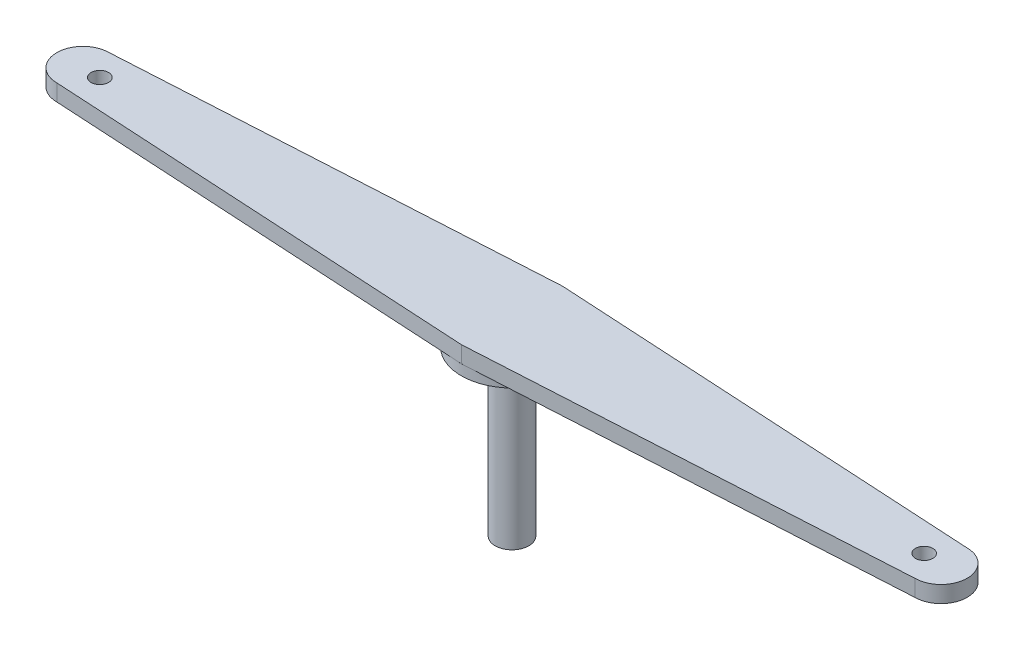
from build123d import *

# Parameters (mm, degrees)
BOSS_EXTRUDE1_DEPTH = 4.75
SKETCH1_4_R         = 4.75
BOSS_EXTRUDE2_DEPTH = 50
SKETCH3_R           = 14.5
BOSS_EXTRUDE3_DEPTH = 3
CUT_EXTRUDE1_REACH  = 56.75
SKETCH4_R           = 2.5
SKETCH5_R           = 2.5
CUT_EXTRUDE2_DEPTH  = 5
SKETCH6_R           = 2.5
BOSS_EXTRUDE5_DEPTH = 5
BOSS_EXTRUDE6_REACH = 56.75
SKETCH7_R           = 4.825
SKETCH8_R           = 2
CUT_EXTRUDE3_DEPTH  = 3


with BuildPart() as part:
    # Sketch1 → Boss-Extrude1 (new body)
    with BuildSketch(Plane(origin=(0, 0, 0), x_dir=(1, 0, 0), z_dir=(0, 1, 0))):
        with BuildLine():
            Line((0, 14.5), (-122.9, 7.5))
            ThreePointArc((-122.9, 7.5), (-130.4, 0), (-122.9, -7.5))
            Line((-122.9, -7.5), (0, -14.5))
            Line((0, -14.5), (122.9, -7.5))
            ThreePointArc((122.9, -7.5), (130.4, 0), (122.9, 7.5))
            Line((122.9, 7.5), (0, 14.5))
        make_face()
    extrude(amount=BOSS_EXTRUDE1_DEPTH)

    # Sketch1_4 → Boss-Extrude2 (add)
    with BuildSketch(Plane(origin=(0, 0, 0), x_dir=(1, 0, 0), z_dir=(0, 1, 0))):
        Circle(SKETCH1_4_R)
    extrude(amount=-BOSS_EXTRUDE2_DEPTH)

    # Sketch3 → Boss-Extrude3 (add)
    with BuildSketch(Plane.XZ):
        Circle(SKETCH3_R)
    extrude(amount=BOSS_EXTRUDE3_DEPTH)

    # Sketch4 → Cut-Extrude1 (cut, up to next)
    with BuildSketch(Plane(origin=(0, 4.75, 0), x_dir=(1, 0, 0), z_dir=(0, 1, 0)), mode=Mode.PRIVATE) as cut_extrude1_sk1:
        with Locations((111.778793877, 0)):
            Circle(SKETCH4_R)
    cut_extrude1_tool1 = extrude(cut_extrude1_sk1.sketch, amount=-CUT_EXTRUDE1_REACH, mode=Mode.PRIVATE) & part.part
    add(cut_extrude1_tool1.solids().sort_by_distance((111.778794, 4.75, 0))[0], mode=Mode.SUBTRACT)
    # Sketch4 → Cut-Extrude1 (cut, up to next)
    with BuildSketch(Plane(origin=(0, 4.75, 0), x_dir=(1, 0, 0), z_dir=(0, 1, 0)), mode=Mode.PRIVATE) as cut_extrude1_sk2:
        with Locations((-118.05968216, 0)):
            Circle(SKETCH4_R)
    cut_extrude1_tool2 = extrude(cut_extrude1_sk2.sketch, amount=-CUT_EXTRUDE1_REACH, mode=Mode.PRIVATE) & part.part
    add(cut_extrude1_tool2.solids().sort_by_distance((-118.059682, 4.75, 0))[0], mode=Mode.SUBTRACT)

    # Sketch5 → Cut-Extrude2 (cut)
    with BuildSketch(Plane(origin=(0, 4.75, 0), x_dir=(1, 0, 0), z_dir=(0, 1, 0))):
        with Locations((-118.05968216, 0)):
            Circle(SKETCH5_R)
        with Locations((118.05968216, 0)):
            Circle(SKETCH5_R)
    extrude(amount=-CUT_EXTRUDE2_DEPTH, mode=Mode.SUBTRACT)

    # Sketch6 → Boss-Extrude5 (add)
    with BuildSketch(Plane(origin=(0, 4.75, 0), x_dir=(1, 0, 0), z_dir=(0, 1, 0))):
        with Locations((111.778793877, 0)):
            Circle(SKETCH6_R)
    extrude(amount=-BOSS_EXTRUDE5_DEPTH)

    # Sketch7 → Boss-Extrude6 (add, up to next)
    with BuildSketch(Plane(origin=(0, -50, 0), x_dir=(-1, 0, 0), z_dir=(0, -1, 0)), mode=Mode.PRIVATE) as boss_extrude6_sk1:
        Circle(SKETCH7_R)
    boss_extrude6_tool1 = extrude(boss_extrude6_sk1.sketch, amount=-BOSS_EXTRUDE6_REACH, mode=Mode.PRIVATE) - part.part
    add(boss_extrude6_tool1.solids().sort_by_distance((0, -50, 0))[0])

    # Sketch8 → Cut-Extrude3 (cut)
    with BuildSketch(Plane.XZ.offset(50)):
        Circle(SKETCH8_R)
    extrude(amount=-CUT_EXTRUDE3_DEPTH, mode=Mode.SUBTRACT)


solid = part.part
